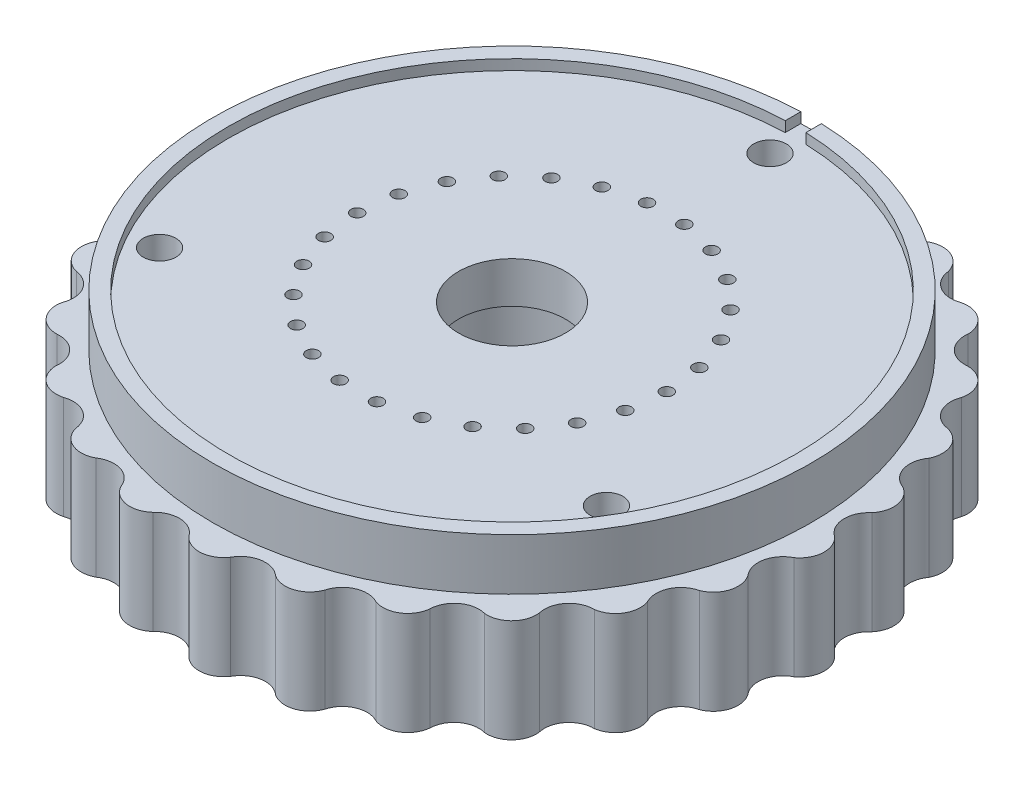
from build123d import *

# Parameters (mm, degrees)
EXTRUDE_WHEEL_DEPTH        = 10
CIRPATTERN1_COUNT          = 26
SKETCH4_R                  = 29
BOSS_EXTRUDE1_DEPTH        = 5
BEARING_HOLE_R             = 5.18
CUT_BEARING_HOLE_DEPTH     = 16
PCB_INSET_CUT_DEPTH        = 1
PCB_INSET_CUT_2_DEPTH      = 1
PCB_OUTPUT_HOLES_R         = 0.6
PCB_OUTPUT_HOLES_CUT_DEPTH = 15
SKETCH5_R                  = 1.5875
ALIGNMENT_PIN_CUTOUT_DEPTH = 15
SKETCH7_R                  = 6.35
CUT_EXTRUDE2_DEPTH         = 9


with BuildPart() as part:
    # Wheel → Extrude wheel (new body)
    with BuildSketch(Plane(origin=(0, 0, 0), x_dir=(1, 0, 0), z_dir=(0, 1, 0))):
        with BuildLine():
            Line((0, 0), (29.128254523, 7.179469929))
            Line((29.128254523, 7.179469929), (30.341931795, 7.478614509))
            ThreePointArc((30.341931795, 7.478614509), (31.616410176, 5.808198613), (31.087663821, 3.774725795))
            ThreePointArc((31.087663821, 3.774725795), (30.249976155, 1.847846509), (31.25, 0))
            Line((31.25, 0), (30, 0))
            Line((30, 0), (0, 0))
        make_face()
    extrude_wheel = extrude(amount=EXTRUDE_WHEEL_DEPTH)

    # CirPattern1: Extrude wheel ×26 about axis
    cirpattern1_axis = Axis((0, 0, 0), (0, 1, 0))
    for i in range(1, CIRPATTERN1_COUNT):
        add(extrude_wheel.rotate(cirpattern1_axis, i * 360 / CIRPATTERN1_COUNT))

    # Sketch4 → Boss-Extrude1 (add)
    with BuildSketch(Plane(origin=(0, 10, 0), x_dir=(1, 0, 0), z_dir=(0, 1, 0))):
        Circle(SKETCH4_R)
    extrude(amount=BOSS_EXTRUDE1_DEPTH)

    # Bearing hole → Cut bearing hole (cut, through all)
    with BuildSketch(Plane(origin=(0, 15, 0), x_dir=(1, 0, 0), z_dir=(0, 1, 0))):
        Circle(BEARING_HOLE_R)
    extrude(amount=-CUT_BEARING_HOLE_DEPTH, mode=Mode.SUBTRACT)

    # PCB inset → PCB inset cut (cut)
    with BuildSketch(Plane(origin=(0, 15, 0), x_dir=(1, 0, 0), z_dir=(0, 1, 0))):
        with BuildLine():
            Line((-1, 27.481812167), (-1, 29.481812167))
            Line((-1, 29.481812167), (1, 29.481812167))
            Line((1, 29.481812167), (1, 27.481812167))
            ThreePointArc((1, 27.481812167), (0, -27.5), (-1, 27.481812167))
        make_face()
    extrude(amount=-PCB_INSET_CUT_DEPTH, mode=Mode.SUBTRACT)

    # PCB inset 2 → PCB inset cut 2 (cut)
    with BuildSketch(Plane.XZ):
        with BuildLine():
            Line((1, -27.481812167), (1, -29.481812167))
            Line((1, -29.481812167), (-1, -29.481812167))
            Line((-1, -29.481812167), (-1, -27.481812167))
            ThreePointArc((-1, -27.481812167), (0, 27.5), (1, -27.481812167))
        make_face()
    extrude(amount=-PCB_INSET_CUT_2_DEPTH, mode=Mode.SUBTRACT)

    # PCB output holes → PCB output holes cut (cut, through all)
    with BuildSketch(Plane(origin=(0, 14, 0), x_dir=(1, 0, 0), z_dir=(0, 1, 0))):
        with Locations((15, 0)):
            Circle(PCB_OUTPUT_HOLES_R)
        with Locations((14.564127261, -3.589734964)):
            Circle(PCB_OUTPUT_HOLES_R)
        with Locations((13.281840385, -6.970847581)):
            Circle(PCB_OUTPUT_HOLES_R)
        with Locations((11.227661223, -9.946839874)):
            Circle(PCB_OUTPUT_HOLES_R)
        with Locations((8.520971201, -12.344757988)):
            Circle(PCB_OUTPUT_HOLES_R)
        with Locations((5.319073306, -14.02524364)):
            Circle(PCB_OUTPUT_HOLES_R)
        with Locations((1.808050204, -14.890633111)):
            Circle(PCB_OUTPUT_HOLES_R)
        with Locations((-1.808050204, -14.890633111)):
            Circle(PCB_OUTPUT_HOLES_R)
        with Locations((-5.319073306, -14.02524364)):
            Circle(PCB_OUTPUT_HOLES_R)
        with Locations((-8.520971201, -12.344757988)):
            Circle(PCB_OUTPUT_HOLES_R)
        with Locations((-11.227661223, -9.946839874)):
            Circle(PCB_OUTPUT_HOLES_R)
        with Locations((-13.281840385, -6.970847581)):
            Circle(PCB_OUTPUT_HOLES_R)
        with Locations((-14.564127261, -3.589734964)):
            Circle(PCB_OUTPUT_HOLES_R)
        with Locations((-15, 0)):
            Circle(PCB_OUTPUT_HOLES_R)
        with Locations((-14.564127261, 3.589734964)):
            Circle(PCB_OUTPUT_HOLES_R)
        with Locations((-13.281840385, 6.970847581)):
            Circle(PCB_OUTPUT_HOLES_R)
        with Locations((-11.227661223, 9.946839874)):
            Circle(PCB_OUTPUT_HOLES_R)
        with Locations((-8.520971201, 12.344757988)):
            Circle(PCB_OUTPUT_HOLES_R)
        with Locations((-5.319073306, 14.02524364)):
            Circle(PCB_OUTPUT_HOLES_R)
        with Locations((-1.808050204, 14.890633111)):
            Circle(PCB_OUTPUT_HOLES_R)
        with Locations((1.808050204, 14.890633111)):
            Circle(PCB_OUTPUT_HOLES_R)
        with Locations((5.319073306, 14.02524364)):
            Circle(PCB_OUTPUT_HOLES_R)
        with Locations((8.520971201, 12.344757988)):
            Circle(PCB_OUTPUT_HOLES_R)
        with Locations((11.227661223, 9.946839874)):
            Circle(PCB_OUTPUT_HOLES_R)
        with Locations((13.281840385, 6.970847581)):
            Circle(PCB_OUTPUT_HOLES_R)
        with Locations((14.564127261, 3.589734964)):
            Circle(PCB_OUTPUT_HOLES_R)
    extrude(amount=-PCB_OUTPUT_HOLES_CUT_DEPTH, mode=Mode.SUBTRACT)

    # Sketch5 → Alignment pin cutout (cut, through all)
    with BuildSketch(Plane.XZ.offset(-1)):
        with Locations((0, -25)):
            Circle(SKETCH5_R)
        with Locations((-21.650635095, 12.5)):
            Circle(SKETCH5_R)
        with Locations((21.650635095, 12.5)):
            Circle(SKETCH5_R)
    extrude(amount=-ALIGNMENT_PIN_CUTOUT_DEPTH, mode=Mode.SUBTRACT)

    # Sketch7 → Cut-Extrude2 (cut)
    with BuildSketch(Plane.XZ.offset(-1)):
        Circle(SKETCH7_R)
    extrude(amount=-CUT_EXTRUDE2_DEPTH, mode=Mode.SUBTRACT)


solid = part.part
